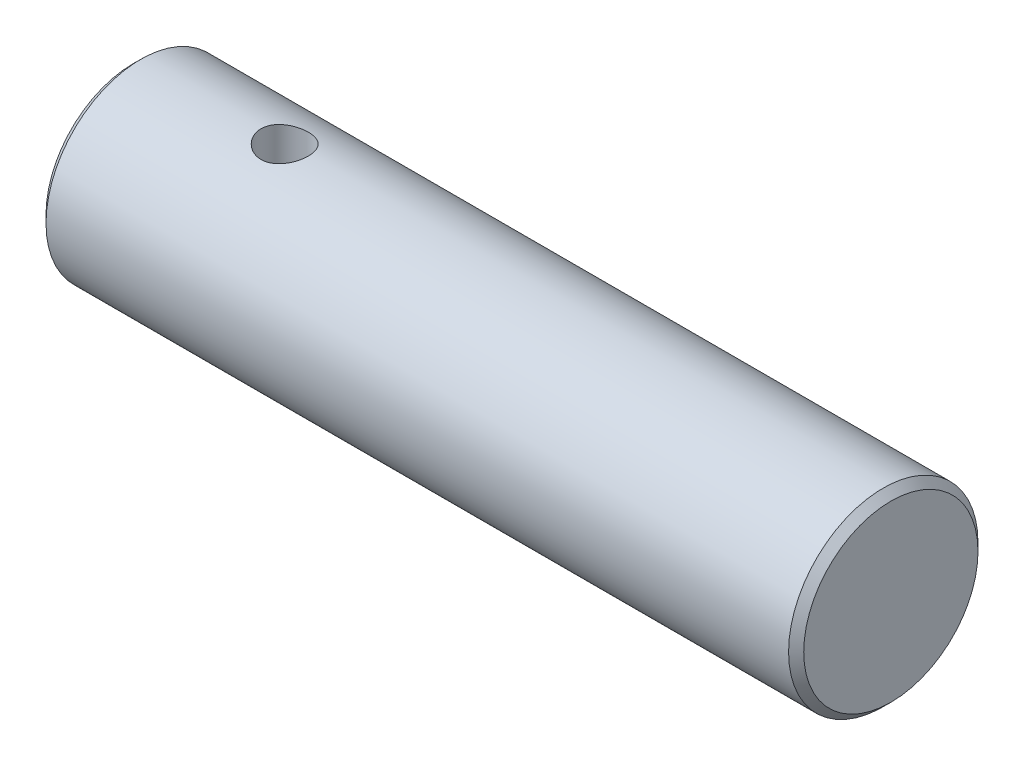
from build123d import *

# Parameters (mm, degrees)
SKETCH2_R               = 3.175
BOSS_EXTRUDE1_DEPTH     = 25.4
CHAMFER1_SIZE           = 0.254
SKETCH4_R               = 0.79375
CUT_EXTRUDE2_DEPTH      = 4.175
CUT_EXTRUDE2_DEPTH_BACK = 4.175


with BuildPart() as part:
    # Sketch2 → Boss-Extrude1 (new body)
    with BuildSketch(Plane(origin=(0, 0, 0), x_dir=(0, 0, -1), z_dir=(1, 0, 0))):
        Circle(SKETCH2_R)
    extrude(amount=BOSS_EXTRUDE1_DEPTH)

    # Chamfer1
    chamfer1_edges = [part.edges().sort_by_distance(p)[0] for p in [
        (0, 0, 3.175),
        (25.4, 0, 3.175),
    ]]
    chamfer(chamfer1_edges, length=CHAMFER1_SIZE)

    # Sketch4 → Cut-Extrude2 (cut, two sides)
    with BuildSketch(Plane(origin=(0, 0, 0), x_dir=(1, 0, 0), z_dir=(0, 1, 0))) as cut_extrude2_sk:
        with Locations((5.08, 0)):
            Circle(SKETCH4_R)
    extrude(amount=CUT_EXTRUDE2_DEPTH, mode=Mode.SUBTRACT)
    extrude(cut_extrude2_sk.sketch, amount=-CUT_EXTRUDE2_DEPTH_BACK, mode=Mode.SUBTRACT)


solid = part.part
